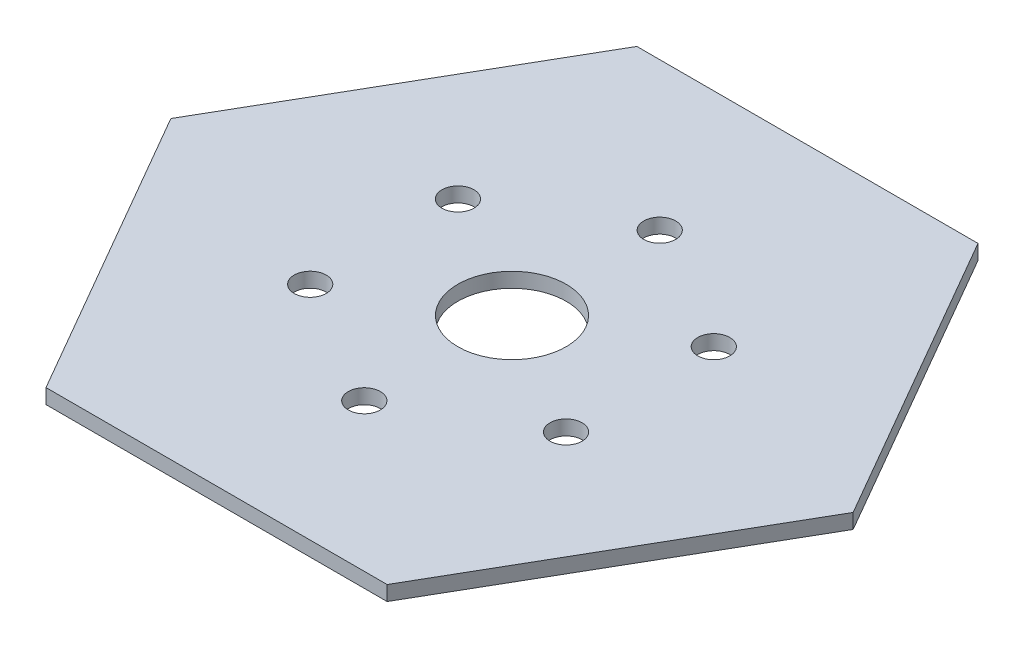
from build123d import *

# Parameters (mm, degrees)
CROQUIS1_R              = 11
SALIENTE_EXTRUIR1_DEPTH = 3
CROQUIS2_R              = 3.25
CORTAR_EXTRUIR1_DEPTH   = 4


with BuildPart() as part:
    # Croquis1 → Saliente-Extruir1 (new body)
    with BuildSketch(Plane(origin=(0, 0, 0), x_dir=(1, 0, 0), z_dir=(0, 1, 0))):
        Polygon((69.282032303, 0), (34.641016151, 60), (-34.641016151, 60), (-69.282032303, 0), (-34.641016151, -60), (34.641016151, -60), align=None)
        Circle(CROQUIS1_R, mode=Mode.SUBTRACT)
    extrude(amount=SALIENTE_EXTRUIR1_DEPTH)

    # Croquis2 → Cortar-Extruir1 (cut, through all)
    with BuildSketch(Plane(origin=(0, 3, 0), x_dir=(1, 0, 0), z_dir=(0, 1, 0))):
        with Locations((0, 30)):
            Circle(CROQUIS2_R)
        with Locations((25.980762114, 15)):
            Circle(CROQUIS2_R)
        with Locations((25.980762114, -15)):
            Circle(CROQUIS2_R)
        with Locations((0, -30)):
            Circle(CROQUIS2_R)
        with Locations((-25.980762114, -15)):
            Circle(CROQUIS2_R)
        with Locations((-25.980762114, 15)):
            Circle(CROQUIS2_R)
    extrude(amount=-CORTAR_EXTRUIR1_DEPTH, mode=Mode.SUBTRACT)


solid = part.part
